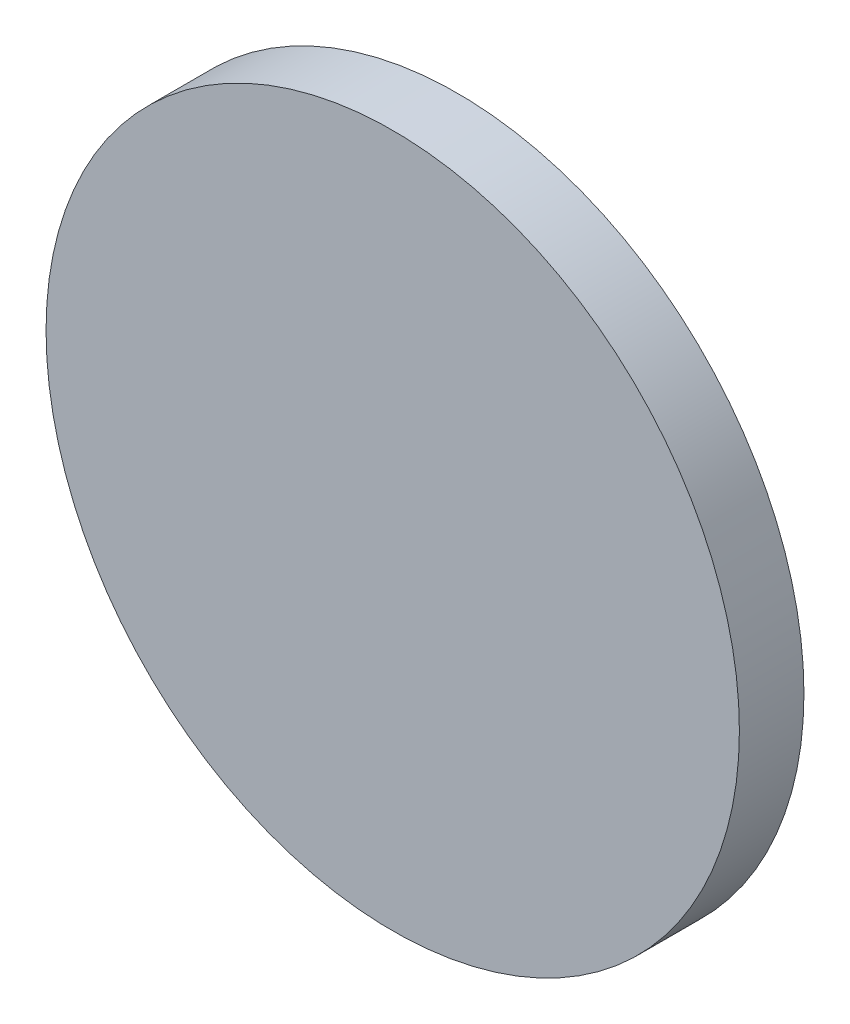
from build123d import *

# Parameters (mm, degrees)
SKETCH1_R           = 9.4
BOSS_EXTRUDE1_DEPTH = 1.75


with BuildPart() as part:
    # Sketch1 → Boss-Extrude1 (new body)
    with BuildSketch(Plane.XY):
        with Locations((-70.225886478, 36.796064436)):
            Circle(SKETCH1_R)
    extrude(amount=BOSS_EXTRUDE1_DEPTH)


solid = part.part
